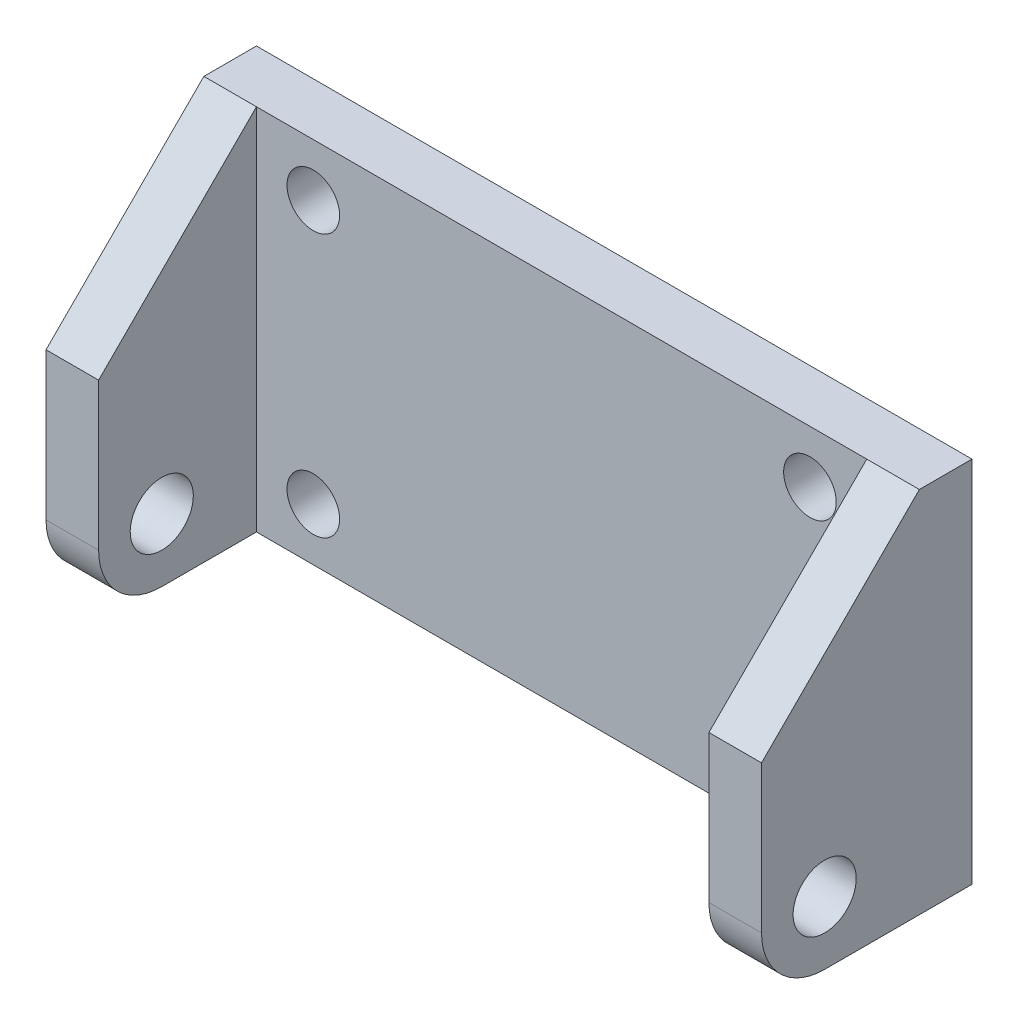
from build123d import *

# Parameters (mm, degrees)
SKETCH1_W           = 34
SKETCH1_H           = 17.5
SKETCH1_R           = 1.25
BOSS_EXTRUDE1_DEPTH = 2.5
SKETCH2_W           = 2.5
SKETCH2_H           = 17.5
BOSS_EXTRUDE2_DEPTH = 7.5
CHAMFER1_SIZE       = 7.5
FILLET1_R           = 3
SKETCH3_R           = 1.5
CUT_EXTRUDE1_DEPTH  = 35


with BuildPart() as part:
    # Sketch1 → Boss-Extrude1 (new body)
    with BuildSketch(Plane.XY):
        with Locations((0.621428571, 4.137142857)):
            Rectangle(SKETCH1_W, SKETCH1_H)
        with Locations((-11.178571429, -2.112857143)):
            Circle(SKETCH1_R, mode=Mode.SUBTRACT)
        with Locations((12.421428571, -2.112857143)):
            Circle(SKETCH1_R, mode=Mode.SUBTRACT)
        with Locations((12.421428571, 10.387142857)):
            Circle(SKETCH1_R, mode=Mode.SUBTRACT)
        with Locations((-11.178571429, 10.387142857)):
            Circle(SKETCH1_R, mode=Mode.SUBTRACT)
    extrude(amount=BOSS_EXTRUDE1_DEPTH)

    # Sketch2 → Boss-Extrude2 (add)
    with BuildSketch(Plane.XY.offset(2.5)):
        with Locations((-15.128571429, 4.137142857)):
            Rectangle(SKETCH2_W, SKETCH2_H)
        with Locations((16.371428571, 4.137142857)):
            Rectangle(SKETCH2_W, SKETCH2_H)
    extrude(amount=BOSS_EXTRUDE2_DEPTH)

    # Chamfer1
    chamfer1_edges = [part.edges().sort_by_distance(p)[0] for p in [
        (16.371428571, 12.887142857, 10),
        (-15.128571429, 12.887142857, 10),
    ]]
    chamfer(chamfer1_edges, length=CHAMFER1_SIZE)

    # Fillet1
    fillet1_edges = [part.edges().sort_by_distance(p)[0] for p in [
        (-15.128571429, -4.612857143, 10),
        (16.371428571, -4.612857143, 10),
    ]]
    fillet(fillet1_edges, radius=FILLET1_R)

    # Sketch3 → Cut-Extrude1 (cut, through all)
    with BuildSketch(Plane(origin=(17.621428571, 0, 0), x_dir=(0, 0, -1), z_dir=(1, 0, 0))):
        with Locations((-7, -1.612857143)):
            Circle(SKETCH3_R)
    extrude(amount=-CUT_EXTRUDE1_DEPTH, mode=Mode.SUBTRACT)


solid = part.part
